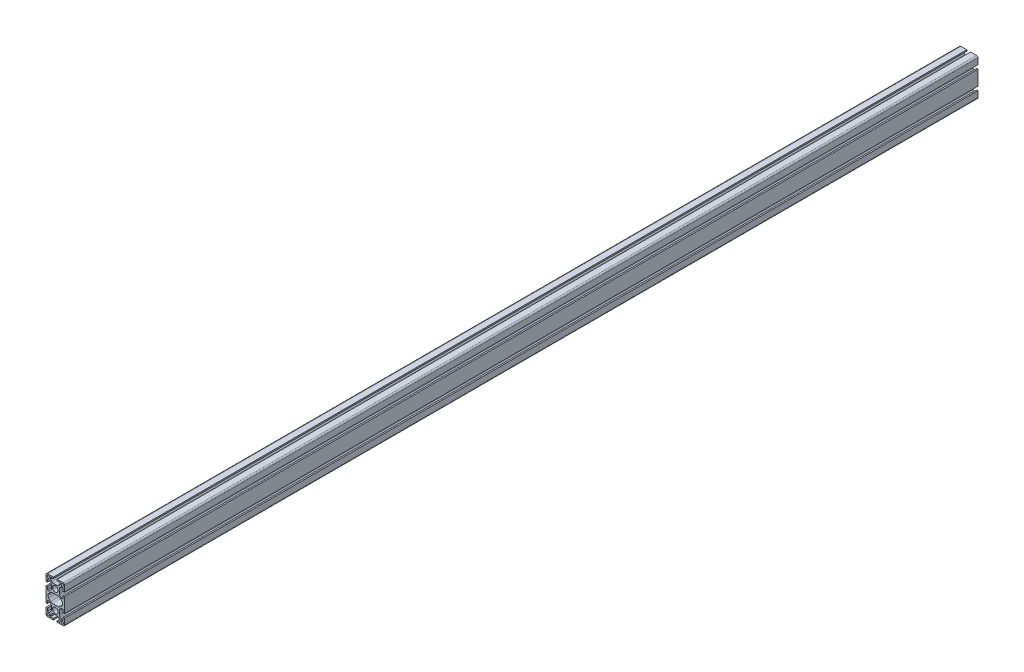
from build123d import *

# Parameters (mm, degrees)
SKETCH1_R           = 2.5
SKETCH1_R_2         = 6
BOSS_EXTRUDE1_DEPTH = 1964


with BuildPart() as part:
    # Sketch1 → Boss-Extrude1 (new body)
    with BuildSketch(Plane.XY):
        with BuildLine():
            Line((-17, -40), (-4.1, -40))
            Line((-4.1, -40), (-4.1, -37))
            Line((-4.1, -37), (-10.5, -37))
            Line((-10.5, -37), (-10.5, -33.6627417))
            ThreePointArc((-10.5, -33.6627417), (-10.378207252, -33.050448208), (-10.03137085, -32.53137085))
            Line((-10.03137085, -32.53137085), (-7.464466094, -29.964466094))
            ThreePointArc((-7.464466094, -29.964466094), (-5.84234935, -28.880602337), (-3.928932188, -28.5))
            Line((-3.928932188, -28.5), (3.928932188, -28.5))
            ThreePointArc((3.928932188, -28.5), (5.84234935, -28.880602337), (7.464466094, -29.964466094))
            Line((7.464466094, -29.964466094), (10.03137085, -32.53137085))
            ThreePointArc((10.03137085, -32.53137085), (10.378207252, -33.050448208), (10.5, -33.6627417))
            Line((10.5, -33.6627417), (10.5, -37))
            Line((10.5, -37), (4.1, -37))
            Line((4.1, -37), (4.1, -40))
            Line((4.1, -40), (17, -40))
            ThreePointArc((17, -40), (19.121320344, -39.121320344), (20, -37))
            Line((20, -37), (20, -24.1))
            Line((20, -24.1), (17, -24.1))
            Line((17, -24.1), (17, -30.5))
            Line((17, -30.5), (13.6627417, -30.5))
            ThreePointArc((13.6627417, -30.5), (13.050448208, -30.378207252), (12.53137085, -30.03137085))
            Line((12.53137085, -30.03137085), (9.964466094, -27.464466094))
            ThreePointArc((9.964466094, -27.464466094), (8.880602337, -25.84234935), (8.5, -23.928932188))
            Line((8.5, -23.928932188), (8.5, -16.071067812))
            ThreePointArc((8.5, -16.071067812), (8.880602337, -14.15765065), (9.964466094, -12.535533906))
            Line((9.964466094, -12.535533906), (12.53137085, -9.96862915))
            ThreePointArc((12.53137085, -9.96862915), (13.050448208, -9.621792748), (13.6627417, -9.5))
            Line((13.6627417, -9.5), (17, -9.5))
            Line((17, -9.5), (17, -15.9))
            Line((17, -15.9), (20, -15.9))
            Line((20, -15.9), (20, 15.9))
            Line((20, 15.9), (17, 15.9))
            Line((17, 15.9), (17, 9.5))
            Line((17, 9.5), (13.6627417, 9.5))
            ThreePointArc((13.6627417, 9.5), (13.050448208, 9.621792748), (12.53137085, 9.96862915))
            Line((12.53137085, 9.96862915), (9.964466094, 12.535533906))
            ThreePointArc((9.964466094, 12.535533906), (8.880602337, 14.15765065), (8.5, 16.071067812))
            Line((8.5, 16.071067812), (8.5, 23.928932188))
            ThreePointArc((8.5, 23.928932188), (8.880602337, 25.84234935), (9.964466094, 27.464466094))
            Line((9.964466094, 27.464466094), (12.53137085, 30.03137085))
            ThreePointArc((12.53137085, 30.03137085), (13.050448208, 30.378207252), (13.6627417, 30.5))
            Line((13.6627417, 30.5), (17, 30.5))
            Line((17, 30.5), (17, 24.1))
            Line((17, 24.1), (20, 24.1))
            Line((20, 24.1), (20, 37))
            ThreePointArc((20, 37), (19.121320344, 39.121320344), (17, 40))
            Line((17, 40), (4.1, 40))
            Line((4.1, 40), (4.1, 37))
            Line((4.1, 37), (10.5, 37))
            Line((10.5, 37), (10.5, 33.6627417))
            ThreePointArc((10.5, 33.6627417), (10.378207252, 33.050448208), (10.03137085, 32.53137085))
            Line((10.03137085, 32.53137085), (7.464466094, 29.964466094))
            ThreePointArc((7.464466094, 29.964466094), (5.84234935, 28.880602337), (3.928932188, 28.5))
            Line((3.928932188, 28.5), (-3.928932188, 28.5))
            ThreePointArc((-3.928932188, 28.5), (-5.84234935, 28.880602337), (-7.464466094, 29.964466094))
            Line((-7.464466094, 29.964466094), (-10.03137085, 32.53137085))
            ThreePointArc((-10.03137085, 32.53137085), (-10.378207252, 33.050448208), (-10.5, 33.6627417))
            Line((-10.5, 33.6627417), (-10.5, 37))
            Line((-10.5, 37), (-4.1, 37))
            Line((-4.1, 37), (-4.1, 40))
            Line((-4.1, 40), (-17, 40))
            ThreePointArc((-17, 40), (-19.121320344, 39.121320344), (-20, 37))
            Line((-20, 37), (-20, 24.1))
            Line((-20, 24.1), (-17, 24.1))
            Line((-17, 24.1), (-17, 30.5))
            Line((-17, 30.5), (-13.6627417, 30.5))
            ThreePointArc((-13.6627417, 30.5), (-13.050448208, 30.378207252), (-12.53137085, 30.03137085))
            Line((-12.53137085, 30.03137085), (-9.964466094, 27.464466094))
            ThreePointArc((-9.964466094, 27.464466094), (-8.880602337, 25.84234935), (-8.5, 23.928932188))
            Line((-8.5, 23.928932188), (-8.5, 16.071067812))
            ThreePointArc((-8.5, 16.071067812), (-8.880602337, 14.15765065), (-9.964466094, 12.535533906))
            Line((-9.964466094, 12.535533906), (-12.53137085, 9.96862915))
            ThreePointArc((-12.53137085, 9.96862915), (-13.050448208, 9.621792748), (-13.6627417, 9.5))
            Line((-13.6627417, 9.5), (-17, 9.5))
            Line((-17, 9.5), (-17, 15.9))
            Line((-17, 15.9), (-20, 15.9))
            Line((-20, 15.9), (-20, -15.9))
            Line((-20, -15.9), (-17, -15.9))
            Line((-17, -15.9), (-17, -9.5))
            Line((-17, -9.5), (-13.6627417, -9.5))
            ThreePointArc((-13.6627417, -9.5), (-13.050448208, -9.621792748), (-12.53137085, -9.96862915))
            Line((-12.53137085, -9.96862915), (-9.964466094, -12.535533906))
            ThreePointArc((-9.964466094, -12.535533906), (-8.880602337, -14.15765065), (-8.5, -16.071067812))
            Line((-8.5, -16.071067812), (-8.5, -23.928932188))
            ThreePointArc((-8.5, -23.928932188), (-8.880602337, -25.84234935), (-9.964466094, -27.464466094))
            Line((-9.964466094, -27.464466094), (-12.53137085, -30.03137085))
            ThreePointArc((-12.53137085, -30.03137085), (-13.050448208, -30.378207252), (-13.6627417, -30.5))
            Line((-13.6627417, -30.5), (-17, -30.5))
            Line((-17, -30.5), (-17, -24.1))
            Line((-17, -24.1), (-20, -24.1))
            Line((-20, -24.1), (-20, -37))
            ThreePointArc((-20, -37), (-19.121320344, -39.121320344), (-17, -40))
        make_face()
        with Locations((15, 35)):
            Circle(SKETCH1_R, mode=Mode.SUBTRACT)
        with Locations((15, -35)):
            Circle(SKETCH1_R, mode=Mode.SUBTRACT)
        with Locations((0, 20)):
            Circle(SKETCH1_R_2, mode=Mode.SUBTRACT)
        with Locations((0, -20)):
            Circle(SKETCH1_R_2, mode=Mode.SUBTRACT)
        with Locations((-15, 35)):
            Circle(SKETCH1_R, mode=Mode.SUBTRACT)
        with Locations((-15, -35)):
            Circle(SKETCH1_R, mode=Mode.SUBTRACT)
        with BuildLine():
            Line((-14.242640687, -4.242640687), (-9.949747468, -8.535533906))
            ThreePointArc((-9.949747468, -8.535533906), (-8.327630724, -9.619397663), (-6.414213562, -10))
            Line((-6.414213562, -10), (6.414213562, -10))
            ThreePointArc((6.414213562, -10), (8.327630724, -9.619397663), (9.949747468, -8.535533906))
            Line((9.949747468, -8.535533906), (14.242640687, -4.242640687))
            ThreePointArc((14.242640687, -4.242640687), (16, 0), (14.242640687, 4.242640687))
            Line((14.242640687, 4.242640687), (9.949747468, 8.535533906))
            ThreePointArc((9.949747468, 8.535533906), (8.327630724, 9.619397663), (6.414213562, 10))
            Line((6.414213562, 10), (-6.414213562, 10))
            ThreePointArc((-6.414213562, 10), (-8.327630724, 9.619397663), (-9.949747468, 8.535533906))
            Line((-9.949747468, 8.535533906), (-14.242640687, 4.242640687))
            ThreePointArc((-14.242640687, 4.242640687), (-16, 0), (-14.242640687, -4.242640687))
        make_face(mode=Mode.SUBTRACT)
    extrude(amount=-BOSS_EXTRUDE1_DEPTH)


solid = part.part
